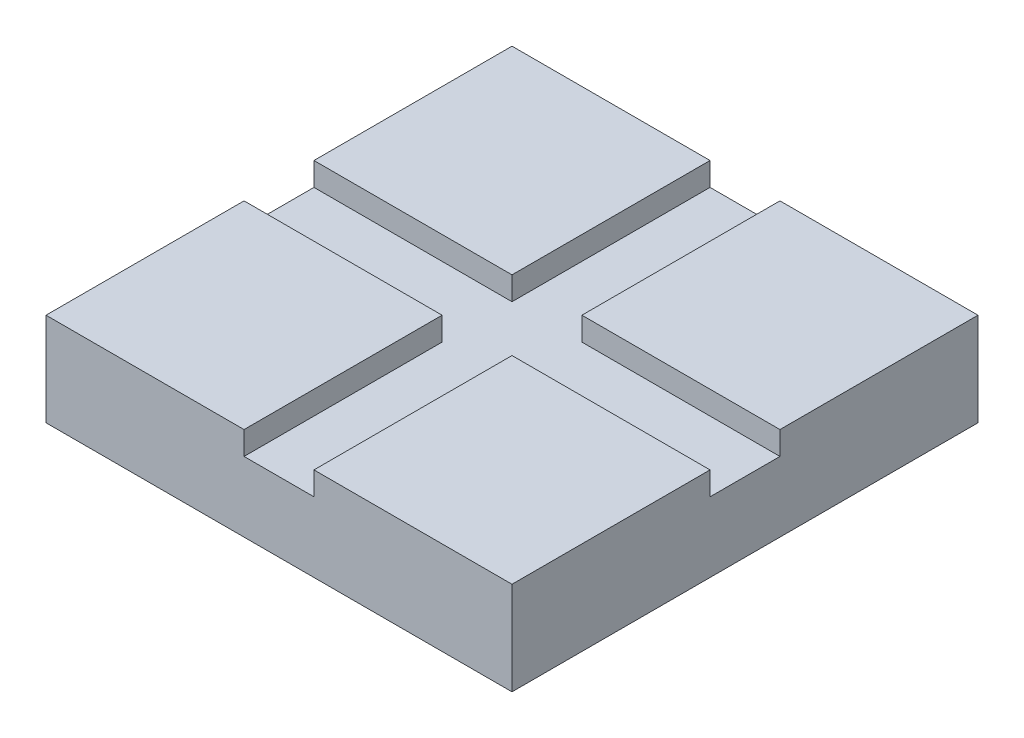
from build123d import *

# Parameters (mm, degrees)
ESBO_O2_W                  = 42.5
ESBO_O2_H                  = 42.5
RESSALTO_EXTRUS_O1_DEPTH   = 20
RESSALTO_EXTRUS_O1_2_DEPTH = 20
RESSALTO_EXTRUS_O1_3_DEPTH = 20
RESSALTO_EXTRUS_O1_4_DEPTH = 20
RESSALTO_EXTRUS_O2_DEPTH   = 15


with BuildPart() as part:
    # Esboço2 → Ressalto-extrusão1 (new body)
    with BuildSketch(Plane(origin=(0, 0, 0), x_dir=(1, 0, 0), z_dir=(0, 1, 0))):
        with Locations((28.75, 28.75)):
            Rectangle(ESBO_O2_W, ESBO_O2_H)
    extrude(amount=RESSALTO_EXTRUS_O1_DEPTH)



with BuildPart() as body_2:
    # Esboço2 → Ressalto-extrus_o1 2 (new body)
    with BuildSketch(Plane(origin=(0, 0, 0), x_dir=(1, 0, 0), z_dir=(0, 1, 0))):
        with Locations((28.75, -28.75)):
            Rectangle(ESBO_O2_W, ESBO_O2_H)
    extrude(amount=RESSALTO_EXTRUS_O1_2_DEPTH)


with BuildPart() as body_3:
    # Esboço2 → Ressalto-extrus_o1 3 (new body)
    with BuildSketch(Plane(origin=(0, 0, 0), x_dir=(1, 0, 0), z_dir=(0, 1, 0))):
        with Locations((-28.75, 28.75)):
            Rectangle(ESBO_O2_W, ESBO_O2_H)
    extrude(amount=RESSALTO_EXTRUS_O1_3_DEPTH)


with BuildPart() as body_4:
    # Esboço2 → Ressalto-extrus_o1 4 (new body)
    with BuildSketch(Plane(origin=(0, 0, 0), x_dir=(1, 0, 0), z_dir=(0, 1, 0))):
        with Locations((-28.75, -28.75)):
            Rectangle(ESBO_O2_W, ESBO_O2_H)
    extrude(amount=RESSALTO_EXTRUS_O1_4_DEPTH)


with BuildPart() as part_1:
    add(part.part)

    add(body_2.part)  # Ressalto-extrusão2 merges body 2

    add(body_3.part)  # Ressalto-extrusão2 merges body 3

    add(body_4.part)  # Ressalto-extrusão2 merges body 4
    # Esboço2<3> → Ressalto-extrusão2 (add)
    with BuildSketch(Plane(origin=(0, 0, 0), x_dir=(1, 0, 0), z_dir=(0, 1, 0))):
        Polygon((50, 7.5), (7.5, 7.5), (7.5, 50), (-7.5, 50), (-7.5, 7.5), (-50, 7.5), (-50, -7.5), (-7.5, -7.5), (-7.5, -50), (7.5, -50), (7.5, -7.5), (50, -7.5), align=None)
    extrude(amount=RESSALTO_EXTRUS_O2_DEPTH)


solid = part_1.part
